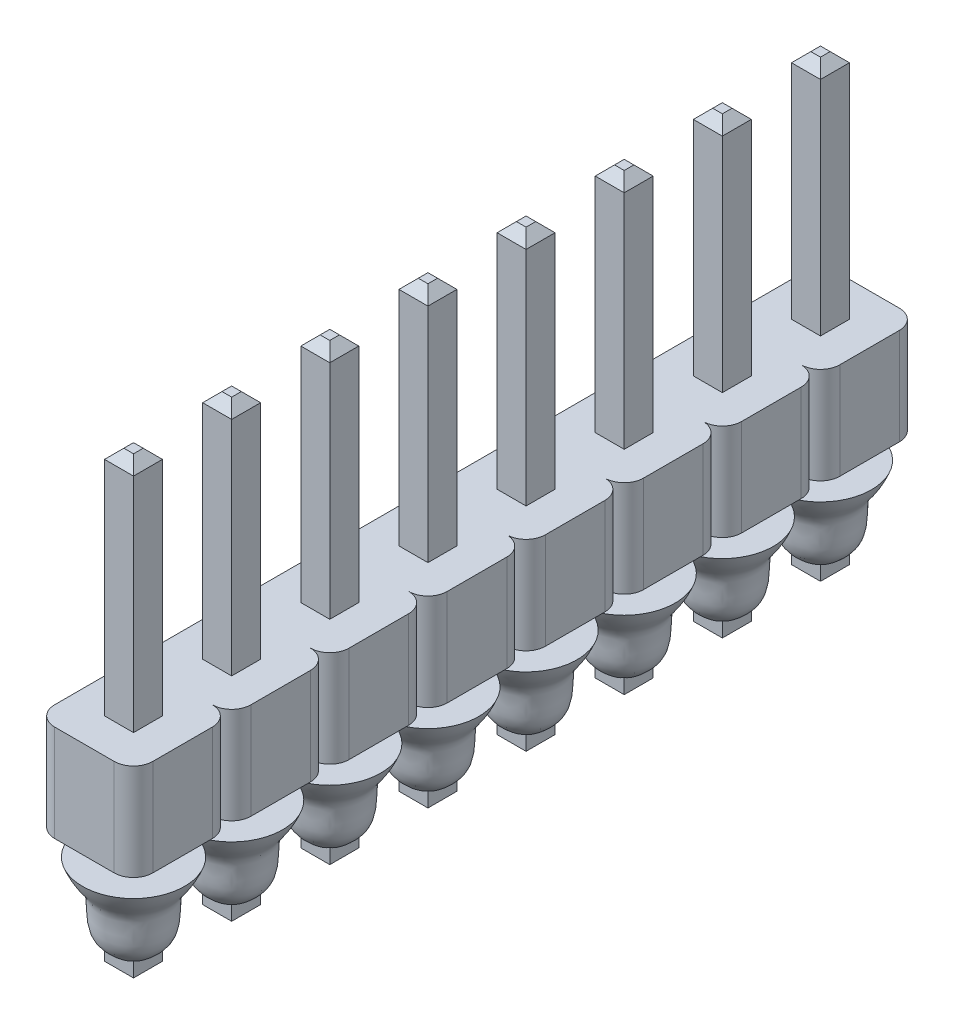
from build123d import *

# Parameters (mm, degrees)
BOSS_EXTRUDE1_DEPTH        = 2.5
LPATTERN1_COUNT            = 8
LPATTERN1_PITCH            = 2.54
BOSS_EXTRUDE2_START        = -3.25
SKETCH2_W                  = 0.75
SKETCH2_H                  = 0.75
BOSS_EXTRUDE2_DEPTH        = 11.75
CHAMFER1_SIZE              = 0.25
LPATTERN2_COUNT            = 8
LPATTERN2_PITCH            = 2.54
CHAMFER1_OF_LPATTERN2_SIZE = 0.25
PADR_O_LINEAR1_COUNT       = 8
PADR_O_LINEAR1_PITCH       = 2.54


with BuildPart() as part:
    # Sketch1 → Boss-Extrude1 (new body)
    with BuildSketch(Plane(origin=(0, 0, 0), x_dir=(-1, 0, 0), z_dir=(0, 1, 0))):
        with BuildLine():
            Line((-0.77, 1.27), (0.77, 1.27))
            ThreePointArc((0.77, 1.27), (1.123553391, 1.123553391), (1.27, 0.77))
            Line((1.27, 0.77), (1.27, -0.77))
            ThreePointArc((1.27, -0.77), (1.123553391, -1.123553391), (0.77, -1.27))
            Line((0.77, -1.27), (-0.77, -1.27))
            ThreePointArc((-0.77, -1.27), (-1.123553391, -1.123553391), (-1.27, -0.77))
            Line((-1.27, -0.77), (-1.27, 0.77))
            ThreePointArc((-1.27, 0.77), (-1.123553391, 1.123553391), (-0.77, 1.27))
        make_face()
    boss_extrude1 = extrude(amount=BOSS_EXTRUDE1_DEPTH)

    # LPattern1: Boss-Extrude1 ×8
    with Locations(*[(0, 0, i * LPATTERN1_PITCH) for i in range(1, LPATTERN1_COUNT)]):
        add(boss_extrude1)

    # Sketch2 → Boss-Extrude2 (add)
    with BuildSketch(Plane(origin=(0, 0, 0), x_dir=(-1, 0, 0), z_dir=(0, 1, 0)).offset(BOSS_EXTRUDE2_START)):
        Rectangle(SKETCH2_W, SKETCH2_H)
    boss_extrude2 = extrude(amount=BOSS_EXTRUDE2_DEPTH)

    # Chamfer1
    chamfer1_edges = [part.edges().sort_by_distance(p)[0] for p in [
        (0.375, -3.25, 0),
        (0, -3.25, 0.375),
        (-0.375, -3.25, 0),
        (0, -3.25, -0.375),
        (0.375, 8.5, 0),
        (0, 8.5, -0.375),
        (-0.375, 8.5, 0),
        (0, 8.5, 0.375),
    ]]
    chamfer(chamfer1_edges, length=CHAMFER1_SIZE)

    # LPattern2: Boss-Extrude2 ×8
    with Locations(*[(0, 0, i * LPATTERN2_PITCH) for i in range(1, LPATTERN2_COUNT)]):
        add(boss_extrude2)

    # Chamfer1 of LPattern2
    chamfer1_of_lpattern2_edges = [part.edges().sort_by_distance(p)[0] for p in [
        (0.375, -3.25, 2.54),
        (0, -3.25, 2.915),
        (-0.375, -3.25, 2.54),
        (0, -3.25, 2.165),
        (0.375, 8.5, 2.54),
        (0, 8.5, 2.165),
        (-0.375, 8.5, 2.54),
        (0, 8.5, 2.915),
        (0.375, -3.25, 5.08),
        (0, -3.25, 5.455),
        (-0.375, -3.25, 5.08),
        (0, -3.25, 4.705),
        (0.375, 8.5, 5.08),
        (0, 8.5, 4.705),
        (-0.375, 8.5, 5.08),
        (0, 8.5, 5.455),
        (0.375, -3.25, 7.62),
        (0, -3.25, 7.995),
        (-0.375, -3.25, 7.62),
        (0, -3.25, 7.245),
        (0.375, 8.5, 7.62),
        (0, 8.5, 7.245),
        (-0.375, 8.5, 7.62),
        (0, 8.5, 7.995),
        (0.375, -3.25, 10.16),
        (0, -3.25, 10.535),
        (-0.375, -3.25, 10.16),
        (0, -3.25, 9.785),
        (0.375, 8.5, 10.16),
        (0, 8.5, 9.785),
        (-0.375, 8.5, 10.16),
        (0, 8.5, 10.535),
        (0.375, -3.25, 12.7),
        (0, -3.25, 13.075),
        (-0.375, -3.25, 12.7),
        (0, -3.25, 12.325),
        (0.375, 8.5, 12.7),
        (0, 8.5, 12.325),
        (-0.375, 8.5, 12.7),
        (0, 8.5, 13.075),
        (0.375, -3.25, 15.24),
        (0, -3.25, 15.615),
        (-0.375, -3.25, 15.24),
        (0, -3.25, 14.865),
        (0.375, 8.5, 15.24),
        (0, 8.5, 14.865),
        (-0.375, 8.5, 15.24),
        (0, 8.5, 15.615),
        (0.375, -3.25, 17.78),
        (0, -3.25, 18.155),
        (-0.375, -3.25, 17.78),
        (0, -3.25, 17.405),
        (0.375, 8.5, 17.78),
        (0, 8.5, 17.405),
        (-0.375, 8.5, 17.78),
        (0, 8.5, 18.155),
    ]]
    chamfer(chamfer1_of_lpattern2_edges, length=CHAMFER1_OF_LPATTERN2_SIZE)

    # Esbo_o1 → Revolu_o2 (revolve)
    with BuildSketch(Plane(origin=(0, 0, 0), x_dir=(-1, 0, 0), z_dir=(0, 0, -1))):
        with BuildLine():
            Line((-1.320204823, -0.661301399), (0, -0.661301399))
            Line((0, -0.661301399), (0, -2.979829628))
            add(Edge.make_bspline(
                [(0, -2.979829628), (-0.667262698, -2.583578616), (-0.826136748, -2.272624234), (-0.856036013, -2.003285061), (-0.876854679, -1.189099082), (-1.10334496, -1.219103696), (-1.320204823, -0.661301399)],
                knots=[0, 0, 0, 0, 0.387503858, 0.628702623, 0.689952237, 1, 1, 1, 1], degree=3))
        make_face()
    revolu_o2 = revolve(axis=Axis((0, -3.204155831, 0), (0, 1, 0)))

    # Padr_o linear1: Revolu_o2 ×8
    with Locations(*[(0, 0, i * PADR_O_LINEAR1_PITCH) for i in range(1, PADR_O_LINEAR1_COUNT)]):
        add(revolu_o2)


solid = part.part
